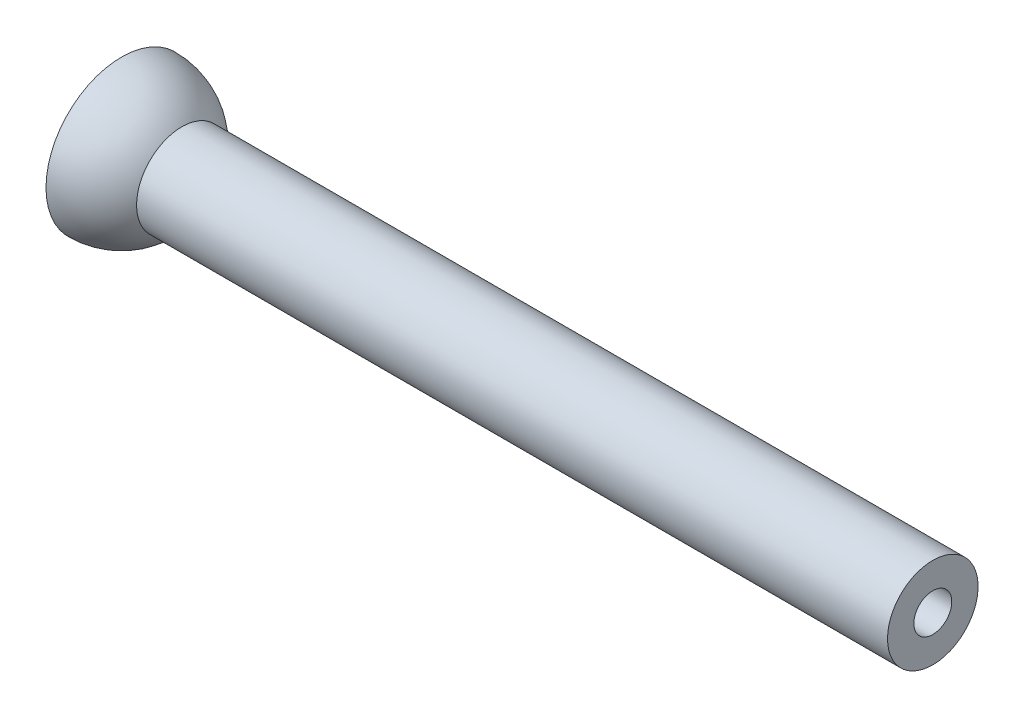
from build123d import *


with BuildPart() as part:
    # Sketch1 → Revolve1 (revolve)
    with BuildSketch(Plane(origin=(0, 0, 0), x_dir=(1, 0, 0), z_dir=(0, 1, 0))):
        with BuildLine():
            Line((0, 12.7), (0, 10.795))
            ThreePointArc((0, 10.795), (7.633217703, 7.633217703), (10.795, 0))
            Line((10.795, 0), (12.7, 0))
            ThreePointArc((12.7, 0), (12.597580707, 1.609646024), (12.291974752, 3.193330031))
            Line((12.291974752, 3.193330031), (136.525, 3.193330031))
            Line((136.525, 3.193330031), (136.525, 7.62))
            Line((136.525, 7.62), (10.16, 7.62))
            ThreePointArc((10.16, 7.62), (5.679612663, 11.359225326), (0, 12.7))
        make_face()
    revolve(axis=Axis((0, 0, 0), (1, 0, 0)))


solid = part.part
